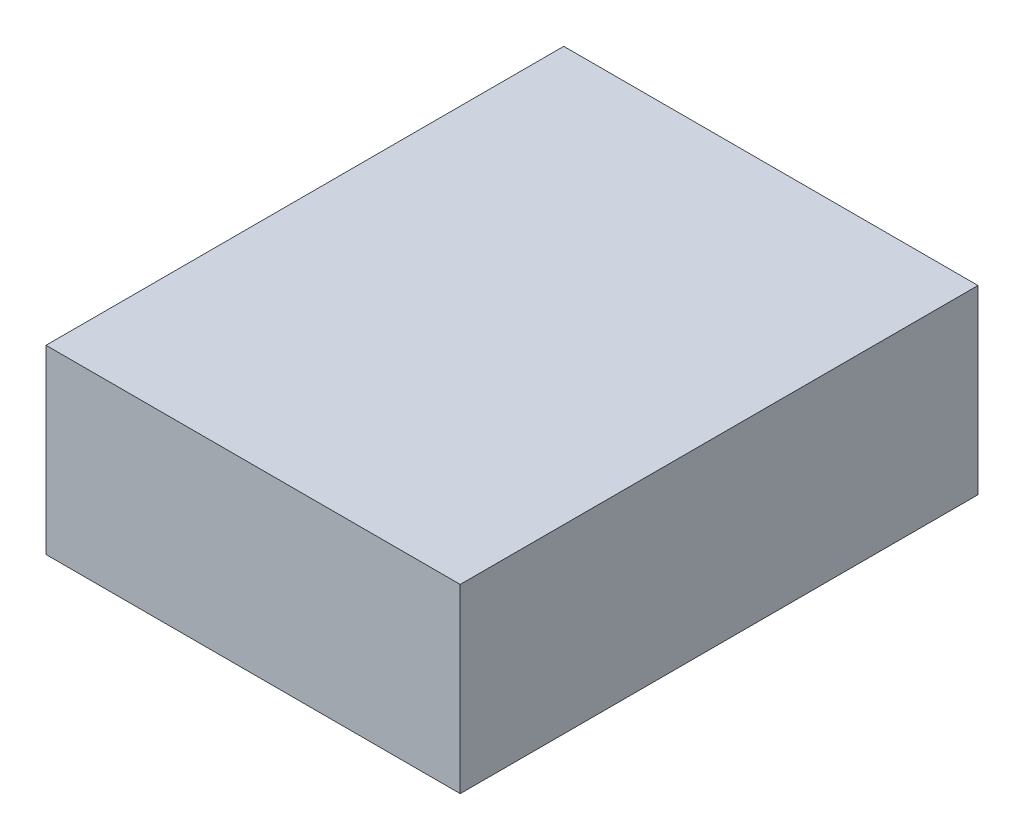
from build123d import *

# Parameters (mm, degrees)
SKIZZE1_W                       = 80
SKIZZE1_H                       = 100
AUFSATZ_LINEAR_AUSTRAGEN1_DEPTH = 35


with BuildPart() as part:
    # Skizze1 → Aufsatz-Linear austragen1 (new body)
    with BuildSketch(Plane(origin=(0, 0, 0), x_dir=(1, 0, 0), z_dir=(0, 1, 0))):
        Rectangle(SKIZZE1_W, SKIZZE1_H)
    extrude(amount=AUFSATZ_LINEAR_AUSTRAGEN1_DEPTH)


solid = part.part
